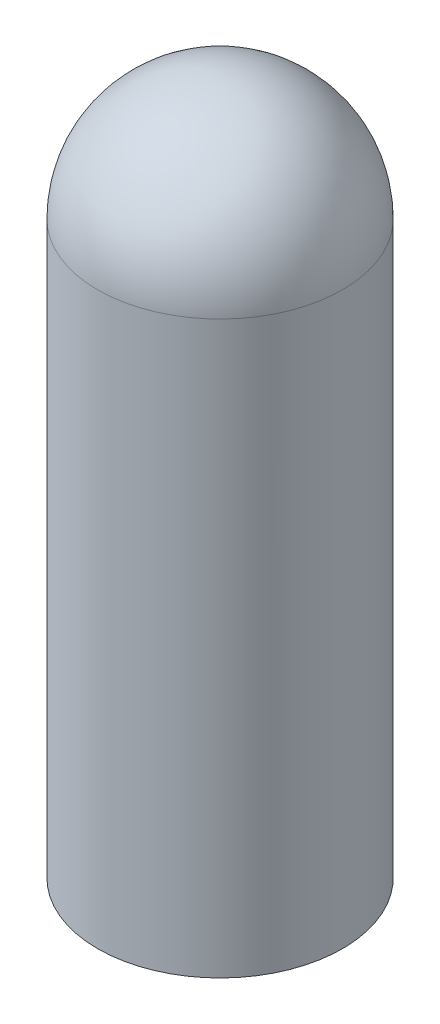
from build123d import *

# Parameters (mm, degrees)
SKETCH2_R          = 6.35
CUT_EXTRUDE1_DEPTH = 31.496


with BuildPart() as part:
    # Sketch1 → Revolve1 (revolve)
    with BuildSketch(Plane.XY):
        with BuildLine():
            Line((-6.731, 0), (-6.731, 31.369))
            ThreePointArc((-6.731, 31.369), (-4.759535744, 36.128535744), (0, 38.1))
            Line((0, 38.1), (0, 0))
            Line((0, 0), (-6.731, 0))
        make_face()
    revolve(axis=Axis((0, 0, 0), (0, -1, 0)))

    # Sketch2 → Cut-Extrude1 (cut)
    with BuildSketch(Plane.XZ):
        Circle(SKETCH2_R)
    extrude(amount=-CUT_EXTRUDE1_DEPTH, mode=Mode.SUBTRACT)


solid = part.part
